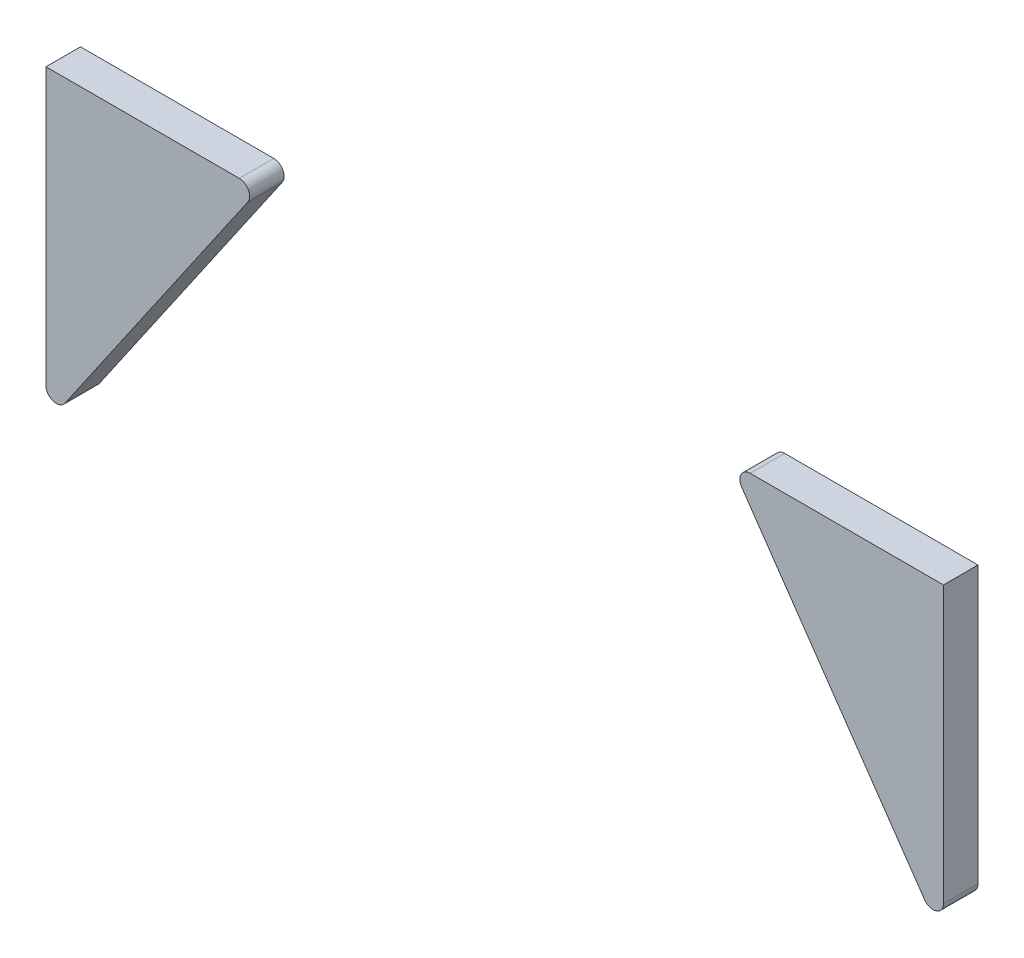
from build123d import *

# Parameters (mm, degrees)
EXTRUDE_1_DEPTH   = 2.5
EXTRUDE_1_2_DEPTH = 2.5


with BuildPart() as part:
    # 스케치1 → 보스-돌출1 (new body, symmetric)
    with BuildSketch(Plane.XY):
        with BuildLine():
            Line((-65, 10.045785441), (-65, 50.045785441))
            Line((-65, 50.045785441), (-37, 50.045785441))
            ThreePointArc((-37, 50.045785441), (-35.672274276, 49.243742747), (-35.764405507, 47.695311309))
            Line((-35.764405507, 47.695311309), (-62.264405507, 9.195311309))
            ThreePointArc((-62.264405507, 9.195311309), (-63.945313519, 8.613411233), (-65, 10.045785441))
        make_face()
    extrude(amount=EXTRUDE_1_DEPTH, both=True)


with BuildPart() as body_2:
    # 스케치1 → Extrude 1 2 (new body, symmetric)
    with BuildSketch(Plane.XY):
        with BuildLine():
            Line((65, 50.045785441), (37, 50.045785441))
            ThreePointArc((37, 50.045785441), (35.672274276, 49.243742747), (35.764405507, 47.695311309))
            Line((35.764405507, 47.695311309), (62.264405507, 9.195311309))
            ThreePointArc((62.264405507, 9.195311309), (63.945313519, 8.613411233), (65, 10.045785441))
            Line((65, 10.045785441), (65, 50.045785441))
        make_face()
    extrude(amount=EXTRUDE_1_2_DEPTH, both=True)


solid = Compound([part.part, body_2.part])
